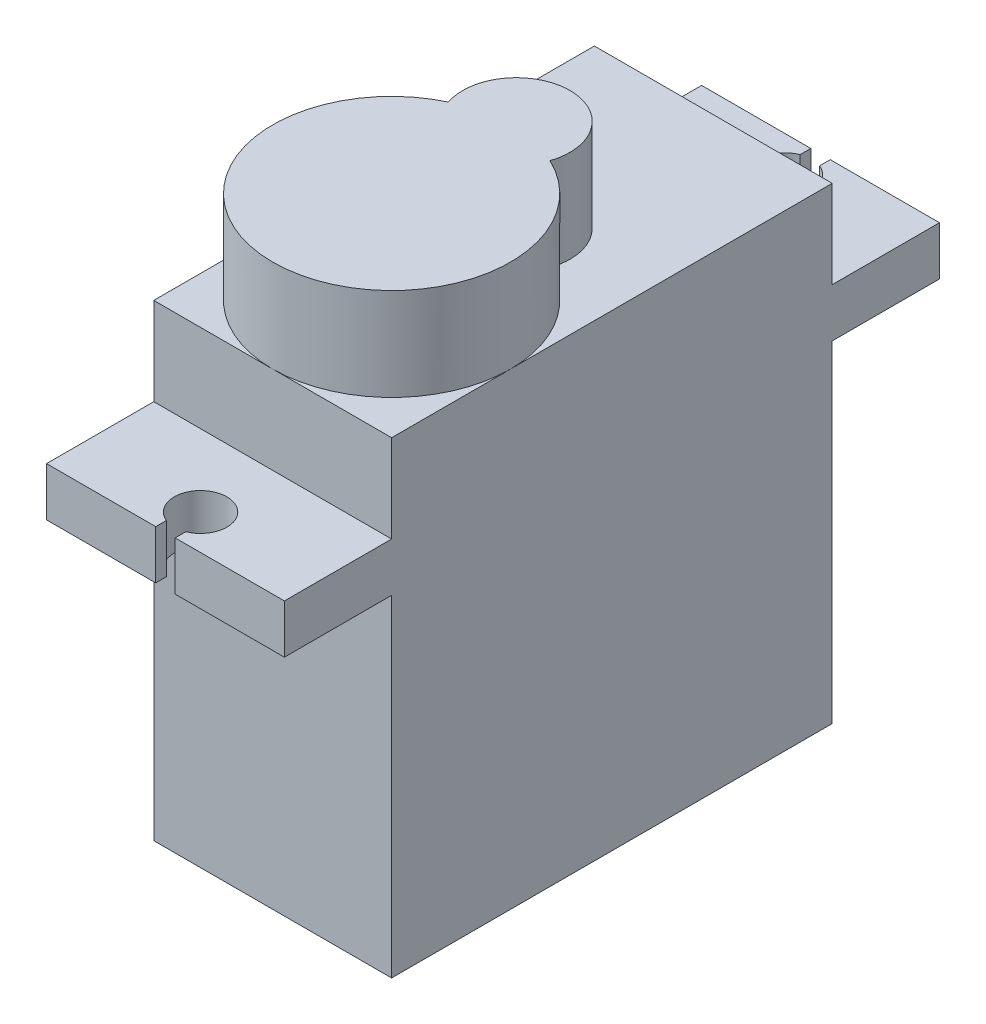
from build123d import *

# Parameters (mm, degrees)
SKETCH1_W           = 12.2
SKETCH1_H           = 22.6
BOSS_EXTRUDE1_DEPTH = 24
BOSS_EXTRUDE2_DEPTH = 2.5
BOSS_EXTRUDE3_DEPTH = 4.75


with BuildPart() as part:
    # Sketch1 → Boss-Extrude1 (new body)
    with BuildSketch(Plane(origin=(0, 0, 0), x_dir=(1, 0, 0), z_dir=(0, 1, 0))):
        with Locations((6.1, 11.3)):
            Rectangle(SKETCH1_W, SKETCH1_H)
    extrude(amount=BOSS_EXTRUDE1_DEPTH)

    # Sketch2 → Boss-Extrude2 (add)
    with BuildSketch(Plane(origin=(0, 19.5, 0), x_dir=(1, 0, 0), z_dir=(0, 1, 0))):
        with BuildLine():
            Line((0, 22.6), (12.2, 22.6))
            Line((12.2, 22.6), (12.2, 28.1))
            Line((12.2, 28.1), (6.6, 28.1))
            Line((6.6, 28.1), (6.6, 27.55399362))
            ThreePointArc((6.6, 27.55399362), (6.1, 24.95), (5.6, 27.55399362))
            Line((5.6, 27.55399362), (5.6, 28.1))
            Line((5.6, 28.1), (0, 28.1))
            Line((0, 28.1), (0, 22.6))
        make_face()
    boss_extrude2 = extrude(amount=-BOSS_EXTRUDE2_DEPTH)

    # Mirror1: Boss-Extrude2 across plane
    add(boss_extrude2.mirror(Plane.XY.offset(-11.3)))

    # Sketch6 → Boss-Extrude3 (add)
    with BuildSketch(Plane(origin=(0, 24, 0), x_dir=(1, 0, 0), z_dir=(0, 1, 0))):
        with BuildLine():
            ThreePointArc((8.704115376, 11.616210937), (6.1, 0), (3.495884624, 11.616210937))
            ThreePointArc((3.495884624, 11.616210937), (6.1, 15.25), (8.704115376, 11.616210937))
        make_face()
    extrude(amount=BOSS_EXTRUDE3_DEPTH)


solid = part.part
